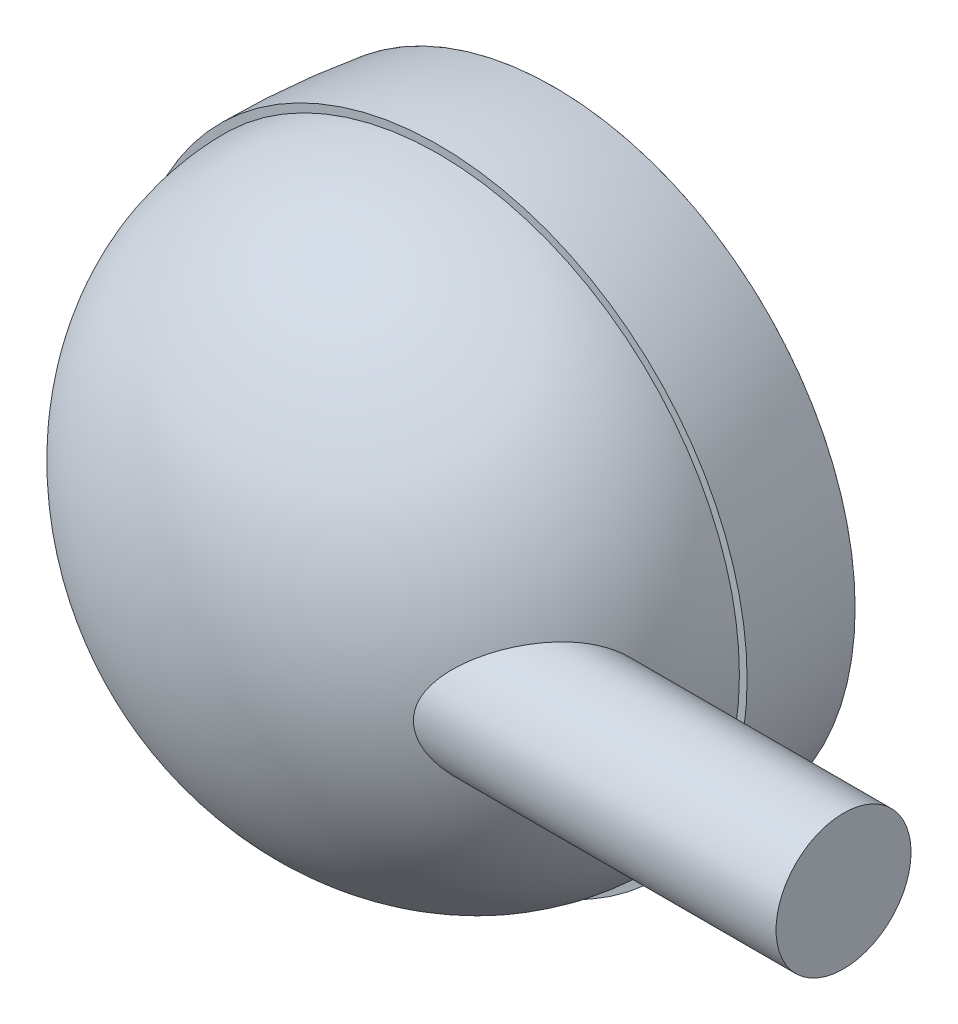
from build123d import *

# Parameters (mm, degrees)
BOSS_EXTRUDE1_REACH = 289.733
BOSS_EXTRUDE1_START = 140
SKETCH7_R           = 17.5


with BuildPart() as part:
    # Sketch5 → Revolve2 (revolve)
    with BuildSketch(Plane(origin=(0, 0, -477.5), x_dir=(0, 0, 1), z_dir=(-1, 0, 0)), mode=Mode.PRIVATE) as revolve2_sk:
        with BuildLine():
            Line((505.5, 75.961651719), (505.5, 77.991071251))
            ThreePointArc((505.5, 77.991071251), (491.468496307, 77.425582442), (477.5, 75.981981251))
            Line((477.5, 75.981981251), (477.5, 78))
            ThreePointArc((477.5, 78), (492.466703622, 79.499445676), (507.5, 80))
            Line((507.5, 80), (507.5, 78))
            add(Edge.make_bspline(
                [(572.5, 0), (572.5, 78), (507.5, 78)],
                knots=[1.570796327, 1.570796327, 1.570796327, 3.141592654, 3.141592654, 3.141592654], degree=2, weights=[1, 0.707106781, 1]))
            Line((572.5, 0), (570.5, 0))
            add(Edge.make_bspline(
                [(570.5, 0), (570.5, 5.08065407), (569.645880459, 15.300550191), (565.856938334, 29.959810075), (559.719978702, 43.409875494), (548.756796512, 58.994503711), (530.674403297, 72.86054026), (513.858495219, 76.282266121), (505.5, 75.961651719)],
                knots=[1.570796327, 1.570796327, 1.570796327, 1.570796327, 1.771140123, 1.97148392, 2.171827716, 2.372171512, 2.772859105, 3.173546698, 3.173546698, 3.173546698, 3.173546698], degree=3))
        make_face()
    revolve(revolve2_sk.sketch.rotate(Axis((0, 0, 0), (0, 0, 1)), 270), axis=Axis((0, 0, 0), (0, 0, 1)))

    # Sketch7 → Boss-Extrude1 (add, up to next)
    with BuildSketch(Plane(origin=(0, 0, 0), x_dir=(0, 0, -1), z_dir=(1, 0, 0)).offset(BOSS_EXTRUDE1_START), mode=Mode.PRIVATE) as boss_extrude1_sk1:
        with Locations((-65, 0)):
            Circle(SKETCH7_R)
    boss_extrude1_tool1 = extrude(boss_extrude1_sk1.sketch, amount=-BOSS_EXTRUDE1_REACH, mode=Mode.PRIVATE) - part.part
    add(boss_extrude1_tool1.solids().sort_by_distance((140, 0, 65))[0])


with BuildPart() as body_2:
    # Sketch6 → Revolve3 (revolve)
    with BuildSketch(Plane(origin=(0, 0, 0), x_dir=(0, 0, -1), z_dir=(1, 0, 0)), mode=Mode.PRIVATE) as revolve3_sk:
        with BuildLine():
            Line((0, 0), (15, 0))
            ThreePointArc((15, 0), (11.2159558, 39.714606885), (0, 78))
            Line((0, 78), (0, 0))
        make_face()
    revolve(revolve3_sk.sketch.rotate(Axis((0, 0, 0), (0, 0, -1)), 90), axis=Axis((0, 0, 0), (0, 0, -1)))


solid = Compound([part.part, body_2.part])
